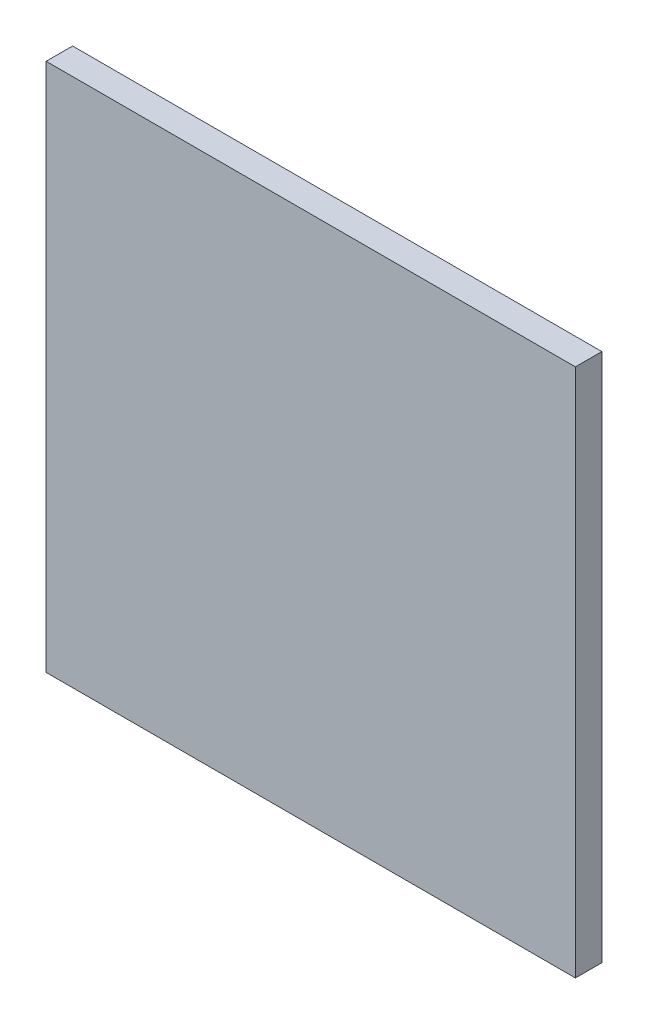
from build123d import *

# Parameters (mm, degrees)
SKETCH5_W           = 10000
SKETCH5_H           = 10000
BOSS_EXTRUDE2_DEPTH = 500


with BuildPart() as part:
    # Sketch5 → Boss-Extrude2 (new body)
    with BuildSketch(Plane.XY):
        with Locations((5000, 5000)):
            Rectangle(SKETCH5_W, SKETCH5_H)
    extrude(amount=-BOSS_EXTRUDE2_DEPTH)


solid = part.part
